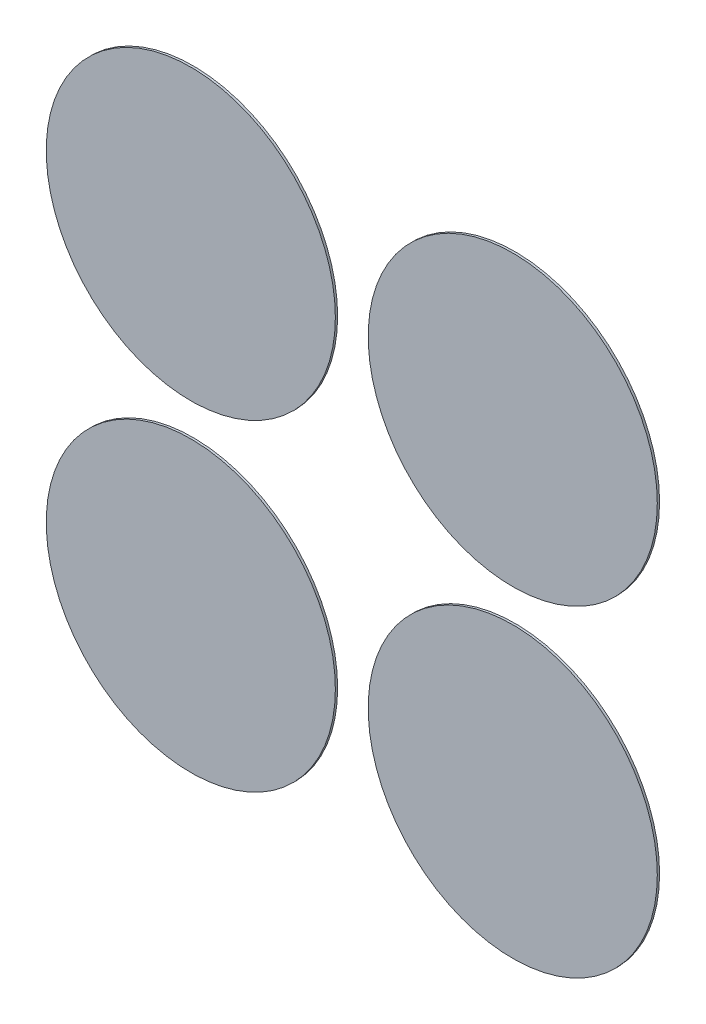
from build123d import *

# Parameters (mm, degrees)
SKETCH1_R             = 6.35
BOSS_EXTRUDE2_DEPTH   = 0.1
BOSS_EXTRUDE2_2_DEPTH = 0.1
BOSS_EXTRUDE2_3_DEPTH = 0.1
BOSS_EXTRUDE2_4_DEPTH = 0.1


with BuildPart() as part:
    # Sketch1 → Boss-Extrude2 (new body)
    with BuildSketch(Plane.XY):
        with Locations((-136.018406204, -83.005064822)):
            Circle(SKETCH1_R)
    extrude(amount=BOSS_EXTRUDE2_DEPTH)


with BuildPart() as body_2:
    # Sketch1 → Boss-Extrude2 2 (new body)
    with BuildSketch(Plane.XY):
        with Locations((-136.018406204, -97.147200445)):
            Circle(SKETCH1_R)
    extrude(amount=BOSS_EXTRUDE2_2_DEPTH)


with BuildPart() as body_3:
    # Sketch1 → Boss-Extrude2 3 (new body)
    with BuildSketch(Plane.XY):
        with Locations((-150.160541828, -97.147200445)):
            Circle(SKETCH1_R)
    extrude(amount=BOSS_EXTRUDE2_3_DEPTH)


with BuildPart() as body_4:
    # Sketch1 → Boss-Extrude2 4 (new body)
    with BuildSketch(Plane.XY):
        with Locations((-150.160541828, -83.005064822)):
            Circle(SKETCH1_R)
    extrude(amount=BOSS_EXTRUDE2_4_DEPTH)


solid = Compound([part.part, body_2.part, body_3.part, body_4.part])
